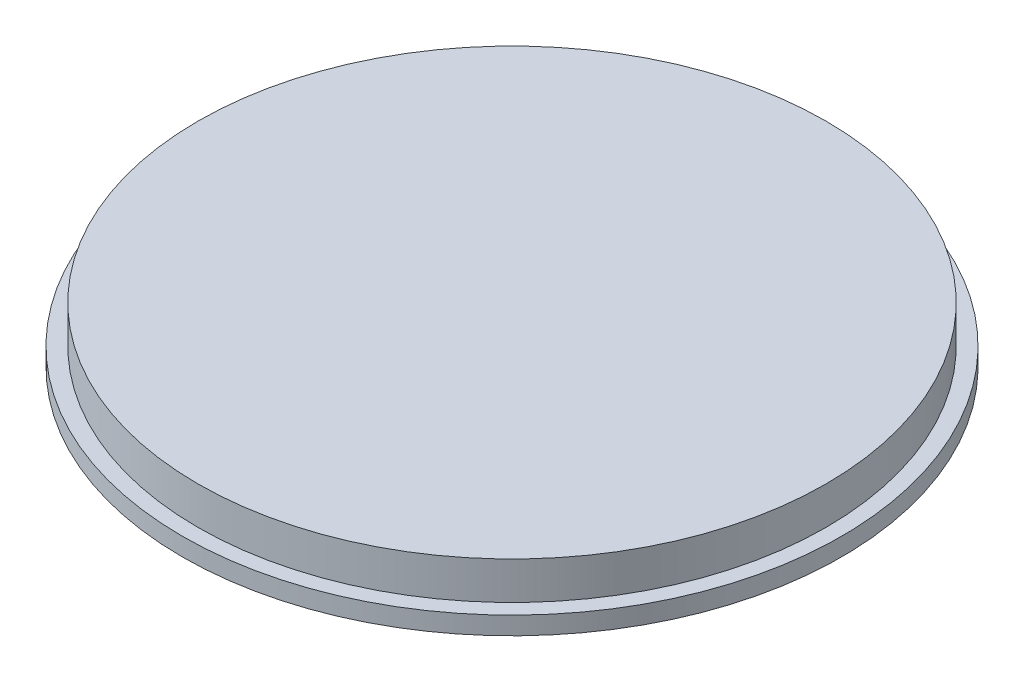
from build123d import *

# Parameters (mm, degrees)
SKETCH1_R      = 466.344
EXTRUDE1_DEPTH = 25.4
SKETCH2_R      = 444.5
EXTRUDE2_DEPTH = 53.34


with BuildPart() as part:
    # Sketch1 → Extrude1 (new body)
    with BuildSketch(Plane(origin=(0, 0, 0), x_dir=(1, 0, 0), z_dir=(0, 1, 0))):
        with Locations(Location((0, 0, 0), (0, 0, 270))):  # turned: the seam where the file's is
            Circle(SKETCH1_R)
    extrude(amount=EXTRUDE1_DEPTH)

    # Sketch2 → Extrude2 (add)
    with BuildSketch(Plane(origin=(0, 25.4, 0), x_dir=(1, 0, 0), z_dir=(0, 1, 0))):
        with Locations(Location((0, 0, 0), (0, 0, 270))):  # turned: the seam where the file's is
            Circle(SKETCH2_R)
    extrude(amount=EXTRUDE2_DEPTH)


solid = part.part
